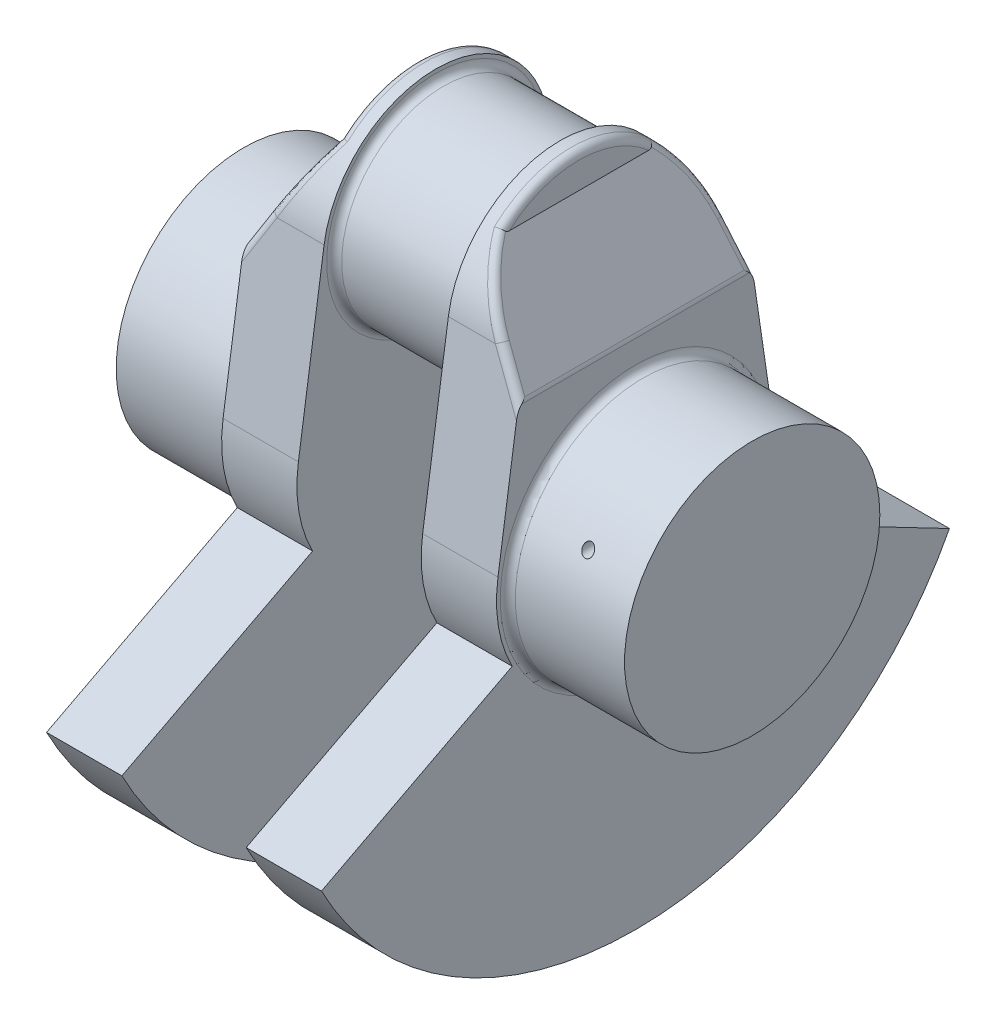
from build123d import *

# Parameters (mm, degrees)
SKETCH_3_R               = 33.9
EXTRUDE_1_DEPTH          = 31
SKETCH_4_R               = 30
SKETCH_4_R_2             = 36.9
SKETCH_4_R_3             = 33.9
EXTRUDE_2_DEPTH          = 20
CUT_EXTRUDE_1_DEPTH      = 84.379018319
CUT_EXTRUDE_1_DEPTH_BACK = 84.379018319
FILLET_1_R               = 2
SKETCH_5_R               = 27
EXTRUDE_3_DEPTH          = 16.5
FILLET_2_R               = 2
FILLET_3_R               = 2
SKETCH_12_R              = 1.5
CUT_EXTRUDE_5_DEPTH      = 95
SKETCH_14_R              = 1.5
CUT_EXTRUDE_6_DEPTH      = 84.379018319
CUT_EXTRUDE_6_DEPTH_BACK = 84.379018319


with BuildPart() as part:
    # Эскиз3 → Бобышка-Вытянуть1 (new body)
    with BuildSketch(Plane(origin=(0, 0, 0), x_dir=(0, 0, -1), z_dir=(1, 0, 0))):
        Circle(SKETCH_3_R)
    extrude(amount=EXTRUDE_1_DEPTH)

    # Эскиз4 → Бобышка-Вытянуть2 (add)
    with BuildSketch(Plane(origin=(31, 0, 0), x_dir=(0, 0, -1), z_dir=(1, 0, 0))):
        with Locations((0, 47.5)):
            Circle(SKETCH_4_R)
        Circle(SKETCH_4_R_2)
        Circle(SKETCH_4_R_2)
        Circle(SKETCH_4_R_3, mode=Mode.SUBTRACT)
        Circle(SKETCH_4_R_3)
        with BuildLine():
            Line((36.508603686, 5.360210526), (29.681791615, 51.857894737))
            ThreePointArc((29.681791615, 51.857894737), (29.920342147, 49.684748447), (30, 47.5))
            ThreePointArc((30, 47.5), (28.276808924, 37.478918368), (23.305194861, 28.609052632))
            ThreePointArc((23.305194861, 28.609052632), (32.086598277, 18.222519338), (36.508603686, 5.360210526))
        make_face()
        with BuildLine():
            ThreePointArc((-23.305194861, 28.609052632), (-28.931511346, 39.564784109), (-29.681791615, 51.857894737))
            Line((-29.681791615, 51.857894737), (-36.508603686, 5.360210526))
            ThreePointArc((-36.508603686, 5.360210526), (-32.086598277, 18.222519338), (-23.305194861, 28.609052632))
        make_face()
        with BuildLine():
            Line((83.379018319, -43.404369644), (0, 0))
            Line((0, 0), (-83.379018319, -43.404369644))
            ThreePointArc((-83.379018319, -43.404369644), (0, -94), (83.379018319, -43.404369644))
        make_face()
    extrude(amount=EXTRUDE_2_DEPTH)

    # Эскиз6 → Вырез-Вытянуть1 (cut, two sides)
    with BuildSketch(Plane.XY) as cut_extrude_1_sk:
        Polygon((31, 77.5), (46, 77.5), (46, 68.5), (31, 42.519237886), align=None)
    extrude(amount=CUT_EXTRUDE_1_DEPTH, mode=Mode.SUBTRACT)
    extrude(cut_extrude_1_sk.sketch, amount=-CUT_EXTRUDE_1_DEPTH_BACK, mode=Mode.SUBTRACT)

    # Скругление1
    fillet_1_edges = [part.edges().sort_by_distance(p)[0] for p in [
        (33.695838023, 47.188566312, 30.367344631),
        (46, 77.5, 0),
        (31, 42.519237886, 0),
        (33.695838023, 47.188566312, -30.367344631),
        (41.495902656, 60.698674559, -26.940582583),
        (41.495902656, 60.698674559, 26.940582583),
    ]]
    fillet(fillet_1_edges, radius=FILLET_1_R)

    # Эскиз5 → Бобышка-Вытянуть3 (add)
    with BuildSketch(Plane(origin=(51, 0, 0), x_dir=(0, 0, -1), z_dir=(1, 0, 0))):
        with Locations((0, 47.5)):
            Circle(SKETCH_5_R)
    extrude(amount=EXTRUDE_3_DEPTH)

    # Скругление2
    fillet_2_edges = [part.edges().sort_by_distance(p)[0] for p in [
        (51, 47.5, 27),
    ]]
    fillet(fillet_2_edges, radius=FILLET_2_R)

    # Скругление3
    fillet_3_edges = [part.edges().sort_by_distance(p)[0] for p in [
        (31, 0, 33.9),
    ]]
    fillet(fillet_3_edges, radius=FILLET_3_R)

    # Зеркальное отражение4: part across plane


with BuildPart() as part_1:
    add(part.part)
    add(part.part.mirror(Plane(origin=(67.5, 47.5, 0), x_dir=(0, 0, 1), z_dir=(1, 0, 0))))

    # Эскиз12 → Вырез-Вытянуть5 (cut)
    with BuildSketch(Plane(origin=(4.83862992, -2.793584287, 0), x_dir=(0, 0, 1), z_dir=(-0.866025404, 0.5, 0))):
        with Locations((0, 74.88620668)):
            Circle(SKETCH_12_R)
    extrude(amount=-CUT_EXTRUDE_5_DEPTH, mode=Mode.SUBTRACT)

    # Эскиз14 → Вырез-Вытянуть6 (cut, two sides)
    with BuildSketch(Plane.XY) as cut_extrude_6_sk:
        with Locations((121, 16.611760598)):
            Circle(SKETCH_14_R)
    extrude(amount=CUT_EXTRUDE_6_DEPTH, mode=Mode.SUBTRACT)
    extrude(cut_extrude_6_sk.sketch, amount=-CUT_EXTRUDE_6_DEPTH_BACK, mode=Mode.SUBTRACT)


solid = part_1.part
